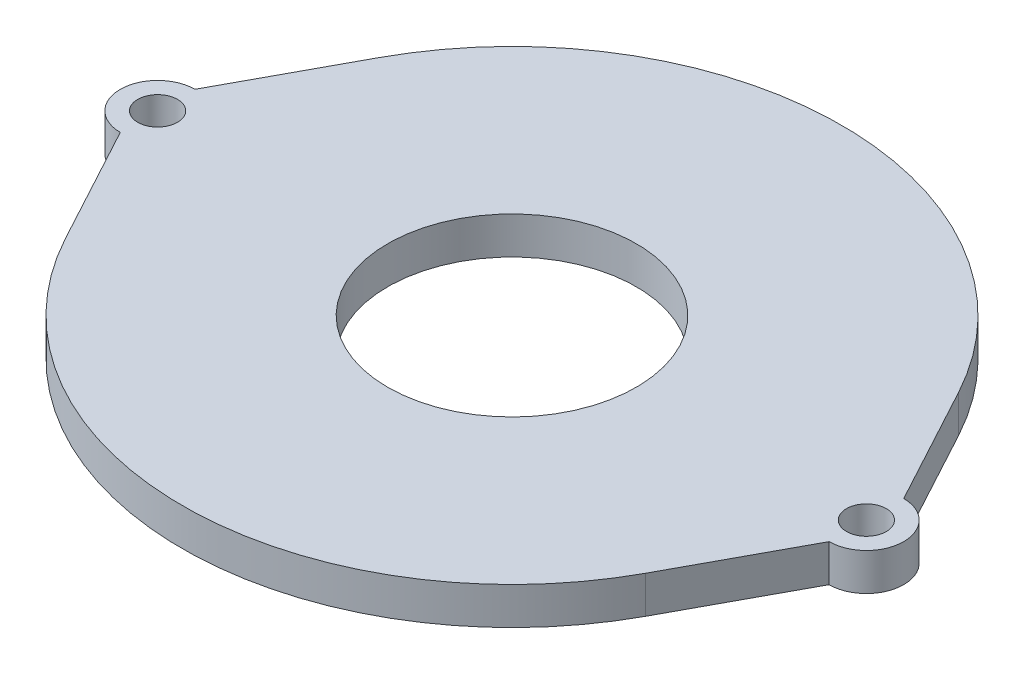
from build123d import *

# Parameters (mm, degrees)
SKETCH1_R                = 10
BOSS_EXTRUDE1_DEPTH      = 3
M3_CLEARANCE_HOLE1_D     = 3.2
M3_CLEARANCE_HOLE1_DEPTH = 3


with BuildPart() as part:
    # Sketch1 → Boss-Extrude1 (new body)
    with BuildSketch(Plane(origin=(0, 0, 0), x_dir=(1, 0, 0), z_dir=(0, 1, 0))):
        with BuildLine():
            Line((-28.5, 3), (-23.314316453, 12.597327031))
            ThreePointArc((-23.314316453, 12.597327031), (0, 26.5), (23.314316453, 12.597327031))
            Line((23.314316453, 12.597327031), (28.5, 3))
            ThreePointArc((28.5, 3), (31.5, 0), (28.5, -3))
            Line((28.5, -3), (23.314316453, -12.597327031))
            ThreePointArc((23.314316453, -12.597327031), (0, -26.5), (-23.314316453, -12.597327031))
            Line((-23.314316453, -12.597327031), (-28.5, -3))
            ThreePointArc((-28.5, -3), (-31.5, 0), (-28.5, 3))
        make_face()
        Circle(SKETCH1_R, mode=Mode.SUBTRACT)
    extrude(amount=-BOSS_EXTRUDE1_DEPTH)

    # M3 Clearance Hole1
    with Locations(Plane(origin=(0, -3, 0), x_dir=(-1, 0, 0), z_dir=(0, -1, 0))):
        with Locations((-28.5, 0), (28.5, 0)):
            Hole(M3_CLEARANCE_HOLE1_D / 2, depth=M3_CLEARANCE_HOLE1_DEPTH)


solid = part.part
